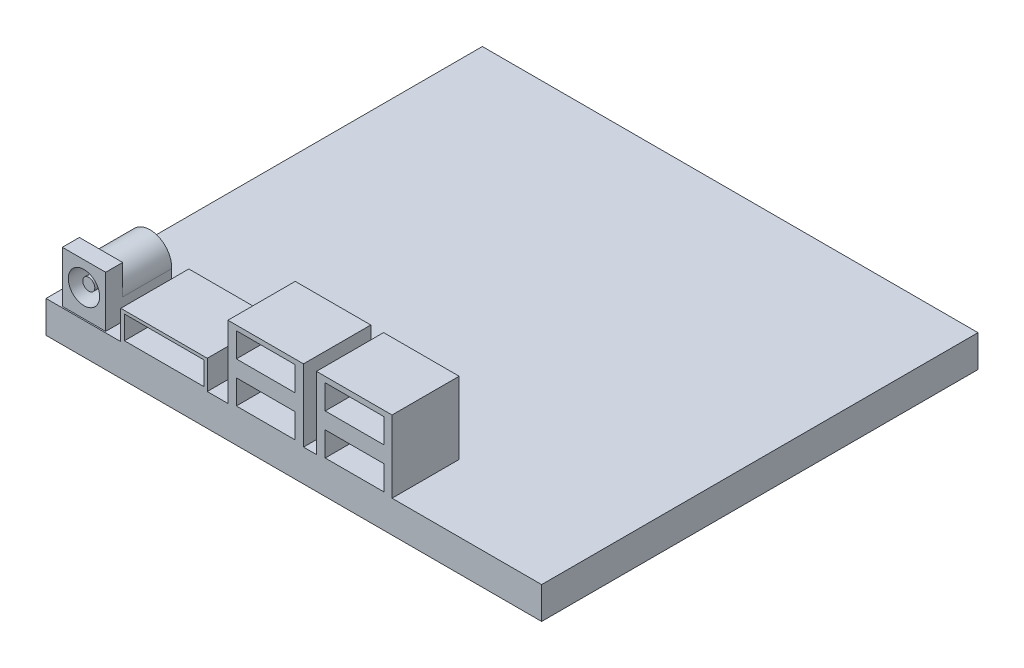
from build123d import *

# Parameters (mm, degrees)
SKETCH1_W           = 103.11
SKETCH1_H           = 90.78
BOSS_EXTRUDE1_DEPTH = 6.65
SKETCH2_W           = 9.01
SKETCH2_H           = 3.54
BOSS_EXTRUDE2_DEPTH = 10.65
BOSS_EXTRUDE3_DEPTH = 10.18
SKETCH4_R           = 3.26
CUT_EXTRUDE1_DEPTH  = 10.18
SKETCH6_R           = 1.25
BOSS_EXTRUDE4_DEPTH = 9.18
SKETCH7_W           = 18
SKETCH7_H           = 14.17
BOSS_EXTRUDE5_DEPTH = 6
SKETCH8_W           = 16.5
SKETCH8_H           = 4.82
CUT_EXTRUDE2_DEPTH  = 9
SKETCH9_W           = 15.72
SKETCH9_H           = 14
BOSS_EXTRUDE6_DEPTH = 15
SKETCH10_W          = 12.25
SKETCH10_H          = 5.08
CUT_EXTRUDE3_DEPTH  = 7.5
SKETCH12_W          = 15.72
SKETCH12_H          = 13.964065117
BOSS_EXTRUDE7_DEPTH = 15
SKETCH13_W          = 12.25
SKETCH13_H          = 5.08
CUT_EXTRUDE4_DEPTH  = 7.5


with BuildPart() as part:
    # Sketch1 → Boss-Extrude1 (new body)
    with BuildSketch(Plane(origin=(0, 0, 0), x_dir=(1, 0, 0), z_dir=(0, 1, 0))):
        Rectangle(SKETCH1_W, SKETCH1_H)
    extrude(amount=BOSS_EXTRUDE1_DEPTH)

    # Sketch2 → Boss-Extrude2 (add)
    with BuildSketch(Plane(origin=(0, 6.65, 0), x_dir=(1, 0, 0), z_dir=(0, 1, 0))):
        with Locations((-43.92, -43.350225169)):
            Rectangle(SKETCH2_W, SKETCH2_H)
    extrude(amount=BOSS_EXTRUDE2_DEPTH)

    # Sketch3 → Boss-Extrude3 (add)
    with BuildSketch(Plane(origin=(0, 0, 41.580225169), x_dir=(-1, 0, 0), z_dir=(0, 0, -1))):
        with BuildLine():
            Line((39.415, 6.65), (39.415, 11.078180036))
            ThreePointArc((39.415, 11.078180036), (43.92, 15.856037514), (48.425, 11.078180036))
            Line((48.425, 11.078180036), (48.425, 6.65))
            Line((48.425, 6.65), (39.415, 6.65))
        make_face()
    extrude(amount=BOSS_EXTRUDE3_DEPTH)

    # Sketch4 → Cut-Extrude1 (cut)
    with BuildSketch(Plane.XY.offset(45.120225169)):
        with Locations((-43.925, 12.286078197)):
            Circle(SKETCH4_R)
    extrude(amount=-CUT_EXTRUDE1_DEPTH, mode=Mode.SUBTRACT)

    # Sketch6 → Boss-Extrude4 (add)
    with BuildSketch(Plane.XY.offset(34.940225169)):
        with Locations((-43.925906585, 12.376780876)):
            Circle(SKETCH6_R)
    extrude(amount=BOSS_EXTRUDE4_DEPTH)

    # Sketch7 → Boss-Extrude5 (add)
    with BuildSketch(Plane(origin=(0, 6.65, 0), x_dir=(1, 0, 0), z_dir=(0, 1, 0))):
        with Locations((-27.007208725, -38.305)):
            Rectangle(SKETCH7_W, SKETCH7_H)
    extrude(amount=BOSS_EXTRUDE5_DEPTH)

    # Sketch8 → Cut-Extrude2 (cut)
    with BuildSketch(Plane.XY.offset(45.39)):
        with Locations((-26.982569048, 9.597847623)):
            Rectangle(SKETCH8_W, SKETCH8_H)
    extrude(amount=-CUT_EXTRUDE2_DEPTH, mode=Mode.SUBTRACT)

    # Sketch9 → Boss-Extrude6 (add)
    with BuildSketch(Plane(origin=(0, 6.65, 0), x_dir=(1, 0, 0), z_dir=(0, 1, 0))):
        with Locations((-5.847208725, -38.39)):
            Rectangle(SKETCH9_W, SKETCH9_H)
    extrude(amount=BOSS_EXTRUDE6_DEPTH)

    # Sketch10 → Cut-Extrude3 (cut)
    with BuildSketch(Plane.XY.offset(45.39)):
        with Locations((-5.831324622, 18.0957287)):
            Rectangle(SKETCH10_W, SKETCH10_H)
        with Locations((-5.831324622, 9.615530297)):
            Rectangle(SKETCH10_W, SKETCH10_H)
    extrude(amount=-CUT_EXTRUDE3_DEPTH, mode=Mode.SUBTRACT)

    # Sketch12 → Boss-Extrude7 (add)
    with BuildSketch(Plane(origin=(0, 6.65, 0), x_dir=(1, 0, 0), z_dir=(0, 1, 0))):
        with Locations((12.572791275, -38.407967442)):
            Rectangle(SKETCH12_W, SKETCH12_H)
    extrude(amount=BOSS_EXTRUDE7_DEPTH)

    # Sketch13 → Cut-Extrude4 (cut)
    with BuildSketch(Plane.XY.offset(45.39)):
        with Locations((12.656700486, 17.962850519)):
            Rectangle(SKETCH13_W, SKETCH13_H)
        with Locations((12.656700486, 9.482652117)):
            Rectangle(SKETCH13_W, SKETCH13_H)
    extrude(amount=-CUT_EXTRUDE4_DEPTH, mode=Mode.SUBTRACT)


solid = part.part
